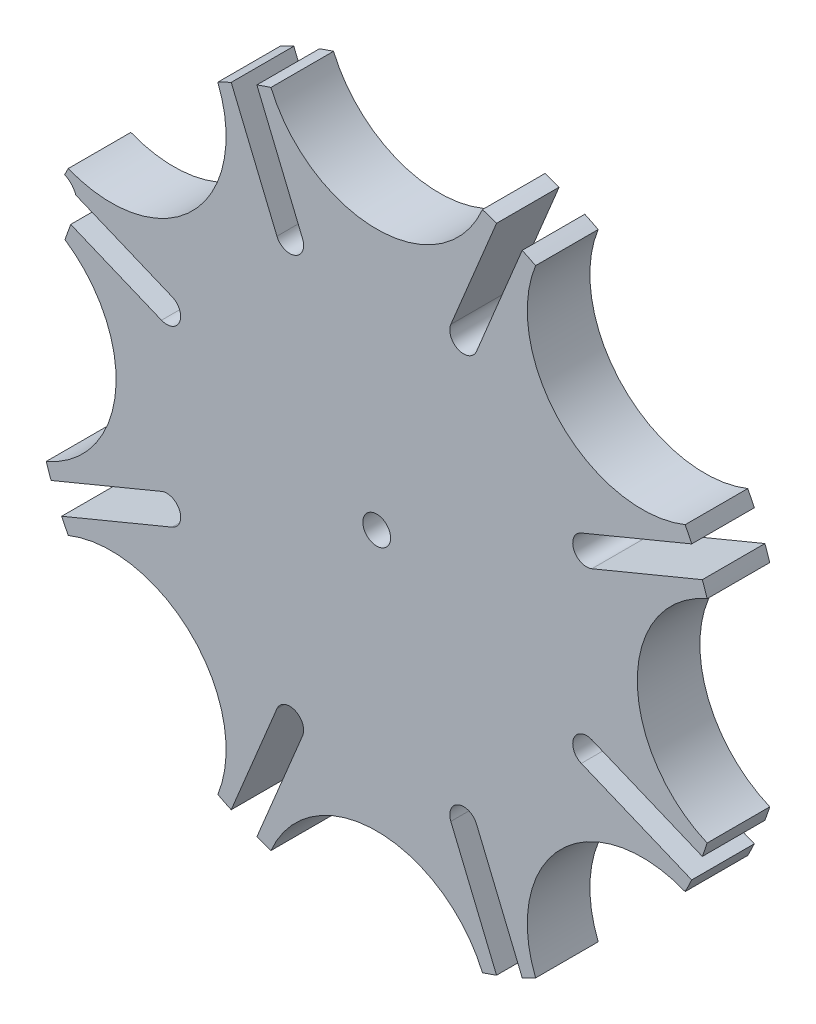
from build123d import *

# Parameters (mm, degrees)
SALIENTE_EXTRUIR1_DEPTH = 3


with BuildPart() as part:
    # Croquis1 → Saliente-Extruir1 (new body)
    with BuildSketch(Plane.XY):
        with BuildLine():
            ThreePointArc((-9.805994702, 4.781775998), (-9.445994702, 4.421775998), (-9.445994702, 3.912659116))
            ThreePointArc((-9.445994702, 3.912659116), (-9.805994702, 3.552659116), (-10.315111585, 3.552659116))
            Line((-10.315111585, 3.552659116), (-14.665897198, 5.354813524))
            Line((-14.665897198, 5.354813524), (-14.942220541, 4.584446936))
            ThreePointArc((-14.942220541, 4.584446936), (-13.141116636, 2.599696402), (-12.489358574, 0))
            ThreePointArc((-12.489358574, 0), (-13.40224475, -3.037731981), (-15.838448045, -5.06900997))
            ThreePointArc((-15.838448045, -5.06900997), (-15.725960944, -5.407906335), (-15.606223383, -5.744309383))
            Line((-15.606223383, -5.744309383), (-10.315111585, -3.552659116))
            ThreePointArc((-10.315111585, -3.552659116), (-9.445994702, -3.912659116), (-9.805994702, -4.781775998))
            Line((-9.805994702, -4.781775998), (-15.0971065, -6.973426265))
            ThreePointArc((-15.0971065, -6.973426265), (-14.943900866, -7.295966383), (-14.78380534, -7.615142693))
            ThreePointArc((-14.78380534, -7.615142693), (-9.642639792, -8.161938898), (-7.217280635, -12.727922061))
            ThreePointArc((-7.217280635, -12.727922061), (-7.317660389, -13.774935704), (-7.615142693, -14.78380534))
            ThreePointArc((-7.615142693, -14.78380534), (-7.295966383, -14.943900866), (-6.973426265, -15.0971065))
            Line((-6.973426265, -15.0971065), (-4.781775998, -9.805994702))
            ThreePointArc((-4.781775998, -9.805994702), (-3.912659116, -9.445994702), (-3.552659116, -10.315111585))
            Line((-3.552659116, -10.315111585), (-5.744309383, -15.606223383))
            ThreePointArc((-5.744309383, -15.606223383), (-5.407906335, -15.725960944), (-5.06900997, -15.838448045))
            ThreePointArc((-5.06900997, -15.838448045), (0, -12.489358574), (5.06900997, -15.838448045))
            ThreePointArc((5.06900997, -15.838448045), (5.407906335, -15.725960944), (5.744309383, -15.606223383))
            Line((5.744309383, -15.606223383), (3.552659116, -10.315111585))
            ThreePointArc((3.552659116, -10.315111585), (3.912659116, -9.445994702), (4.781775998, -9.805994702))
            Line((4.781775998, -9.805994702), (6.973426265, -15.0971065))
            ThreePointArc((6.973426265, -15.0971065), (7.295966383, -14.943900866), (7.615142693, -14.78380534))
            ThreePointArc((7.615142693, -14.78380534), (8.83131014, -8.83131014), (14.78380534, -7.615142693))
            ThreePointArc((14.78380534, -7.615142693), (14.943900866, -7.295966383), (15.0971065, -6.973426265))
            Line((15.0971065, -6.973426265), (9.805994702, -4.781775998))
            ThreePointArc((9.805994702, -4.781775998), (9.445994702, -3.912659116), (10.315111585, -3.552659116))
            Line((10.315111585, -3.552659116), (15.606223383, -5.744309383))
            ThreePointArc((15.606223383, -5.744309383), (15.725960944, -5.407906335), (15.838448045, -5.06900997))
            ThreePointArc((15.838448045, -5.06900997), (12.489358574, 0), (15.838448045, 5.06900997))
            ThreePointArc((15.838448045, 5.06900997), (15.725960944, 5.407906335), (15.606223383, 5.744309383))
            Line((15.606223383, 5.744309383), (10.315111585, 3.552659116))
            ThreePointArc((10.315111585, 3.552659116), (9.445994702, 3.912659116), (9.805994702, 4.781775998))
            Line((9.805994702, 4.781775998), (15.0971065, 6.973426265))
            ThreePointArc((15.0971065, 6.973426265), (14.943900866, 7.295966383), (14.78380534, 7.615142693))
            ThreePointArc((14.78380534, 7.615142693), (8.83131014, 8.83131014), (7.615142693, 14.78380534))
            ThreePointArc((7.615142693, 14.78380534), (7.295966383, 14.943900866), (6.973426265, 15.0971065))
            Line((6.973426265, 15.0971065), (4.781775998, 9.805994702))
            ThreePointArc((4.781775998, 9.805994702), (3.912659116, 9.445994702), (3.552659116, 10.315111585))
            Line((3.552659116, 10.315111585), (5.744309383, 15.606223383))
            ThreePointArc((5.744309383, 15.606223383), (5.407906335, 15.725960944), (5.06900997, 15.838448045))
            ThreePointArc((5.06900997, 15.838448045), (0, 12.489358574), (-5.06900997, 15.838448045))
            ThreePointArc((-5.06900997, 15.838448045), (-5.407906335, 15.725960944), (-5.744309383, 15.606223383))
            Line((-5.744309383, 15.606223383), (-3.552659116, 10.315111585))
            ThreePointArc((-3.552659116, 10.315111585), (-3.912659116, 9.445994702), (-4.781775998, 9.805994702))
            Line((-4.781775998, 9.805994702), (-6.973426265, 15.0971065))
            ThreePointArc((-6.973426265, 15.0971065), (-7.295966383, 14.943900866), (-7.615142693, 14.78380534))
            ThreePointArc((-7.615142693, 14.78380534), (-7.317660389, 13.774935704), (-7.217280635, 12.727922061))
            ThreePointArc((-7.217280635, 12.727922061), (-9.642639792, 8.161938898), (-14.78380534, 7.615142693))
            ThreePointArc((-14.78380534, 7.615142693), (-14.870201448, 7.445025684), (-14.954640105, 7.273928642))
            ThreePointArc((-14.954640105, 7.273928642), (-14.628849784, 7.038643274), (-14.422305364, 6.693914482))
            Line((-14.422305364, 6.693914482), (-9.805994702, 4.781775998))
        make_face()
        with BuildLine():
            ThreePointArc((0.665193263, 0), (-0.129772768, -0.652411761), (-0.614558441, 0.254558441))
            ThreePointArc((-0.614558441, 0.254558441), (0.129772768, 0.652411761), (0.665193263, 0))
        make_face(mode=Mode.SUBTRACT)
    extrude(amount=-SALIENTE_EXTRUIR1_DEPTH)


solid = part.part
